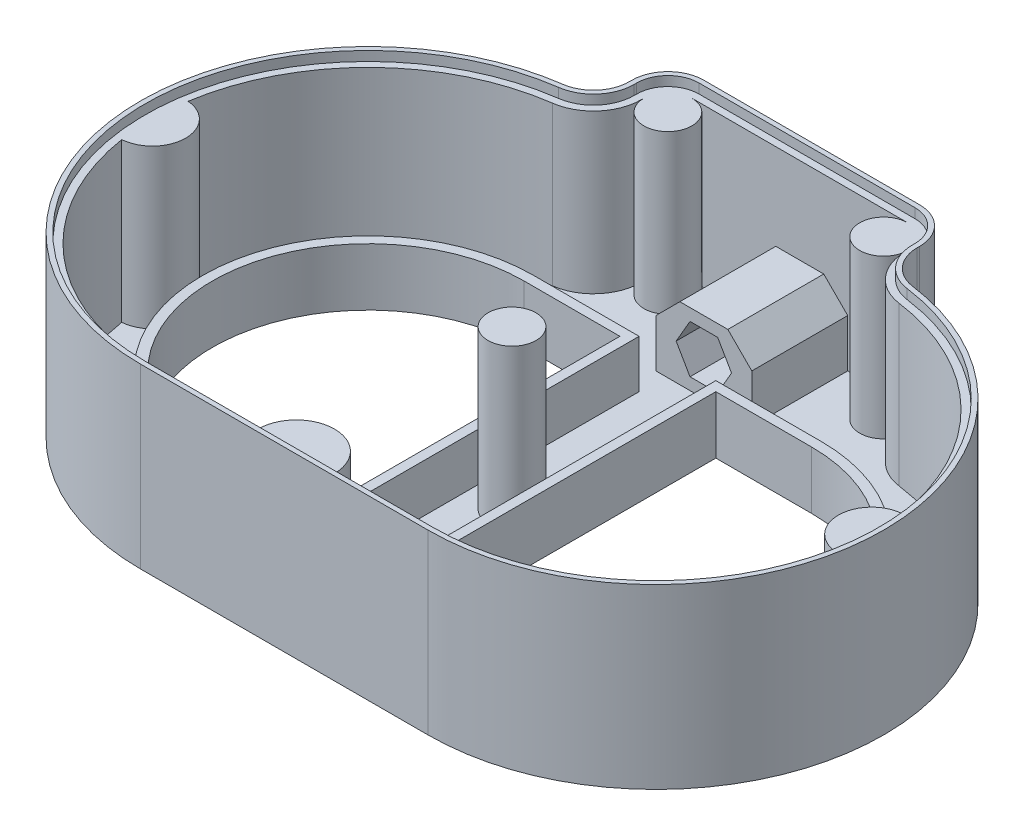
from build123d import *

# Parameters (mm, degrees)
BOSS_EXTRUDE1_DEPTH = 2
EXTRUDE_THIN1_DEPTH = 35
EXTRUDE_THIN3_DEPTH = 10
EXTRUDE_THIN4_DEPTH = 33
BOSS_EXTRUDE4_DEPTH = 33
BOSS_EXTRUDE5_DEPTH = 33
SKETCH12_R          = 5
BOSS_EXTRUDE7_DEPTH = 33
SKETCH13_W          = 20
SKETCH13_H          = 20
BOSS_EXTRUDE8_DEPTH = 15
CUT_EXTRUDE1_DEPTH  = 28
CHAMFER2_SIZE       = 5
SKETCH17_R          = 5
BOSS_EXTRUDE9_DEPTH = 33


with BuildPart() as part:
    # Sketch1 → Boss-Extrude1 (new body)
    with BuildSketch(Plane(origin=(0, 0, 0), x_dir=(1, 0, 0), z_dir=(0, 1, 0))):
        with BuildLine():
            Line((-30, 54.486236794), (-30, 55))
            ThreePointArc((-30, 55), (-27.803300859, 60.303300859), (-22.5, 62.5))
            Line((-22.5, 62.5), (22.5, 62.5))
            ThreePointArc((22.5, 62.5), (27.803300859, 60.303300859), (30, 55))
            Line((30, 55), (30, 54.486236794))
            ThreePointArc((30, 54.486236794), (31.846662289, 49.557771239), (36.477272727, 47.056295413))
            ThreePointArc((36.477272727, 47.056295413), (77.388944028, -3.246226107), (30, -47.5))
            Line((30, -47.5), (-30, -47.5))
            ThreePointArc((-30, -47.5), (-77.388944028, -3.246226107), (-36.477272727, 47.056295413))
            ThreePointArc((-36.477272727, 47.056295413), (-31.846662289, 49.557771239), (-30, 54.486236794))
        make_face()
        with BuildLine():
            Line((-30, 32.5), (-10, 32.5))
            Line((-10, 32.5), (-10, -32.5))
            Line((-10, -32.5), (-30, -32.5))
            ThreePointArc((-30, -32.5), (-62.5, 0), (-30, 32.5))
        make_face(mode=Mode.SUBTRACT)
        with BuildLine():
            Line((10, 32.5), (30, 32.5))
            ThreePointArc((30, 32.5), (62.5, 0), (30, -32.5))
            Line((30, -32.5), (10, -32.5))
            Line((10, -32.5), (10, 32.5))
        make_face(mode=Mode.SUBTRACT)
    extrude(amount=BOSS_EXTRUDE1_DEPTH)

    # Sketch2 → Extrude-Thin1 (add)
    with BuildSketch(Plane(origin=(0, 2, 0), x_dir=(1, 0, 0), z_dir=(0, 1, 0))):
        with BuildLine():
            Line((-30, -47.5), (30, -47.5))
            ThreePointArc((30, -47.5), (77.388944028, -3.246226107), (36.477272727, 47.056295413))
            ThreePointArc((36.477272727, 47.056295413), (31.846662289, 49.557771239), (30, 54.486236794))
            Line((30, 54.486236794), (30, 55))
            ThreePointArc((30, 55), (27.803300859, 60.303300859), (22.5, 62.5))
            Line((22.5, 62.5), (-22.5, 62.5))
            ThreePointArc((-22.5, 62.5), (-27.803300859, 60.303300859), (-30, 55))
            Line((-30, 55), (-30, 54.486236794))
            ThreePointArc((-30, 54.486236794), (-31.846662289, 49.557771239), (-36.477272727, 47.056295413))
            ThreePointArc((-36.477272727, 47.056295413), (-77.388944028, -3.246226107), (-30, -47.5))
        make_face()
        with BuildLine():
            Line((-30, -46.5), (30, -46.5))
            ThreePointArc((30, -46.5), (76.391282048, -3.177884504), (36.340909091, 46.065636562))
            ThreePointArc((36.340909091, 46.065636562), (31.092883928, 48.900642499), (29, 54.486236794))
            Line((29, 54.486236794), (29, 55))
            ThreePointArc((29, 55), (27.096194078, 59.596194078), (22.5, 61.5))
            Line((22.5, 61.5), (-22.5, 61.5))
            ThreePointArc((-22.5, 61.5), (-27.096194078, 59.596194078), (-29, 55))
            Line((-29, 55), (-29, 54.486236794))
            ThreePointArc((-29, 54.486236794), (-31.092883928, 48.900642499), (-36.340909091, 46.065636562))
            ThreePointArc((-36.340909091, 46.065636562), (-76.391282048, -3.177884504), (-30, -46.5))
        make_face(mode=Mode.SUBTRACT)
    extrude(amount=EXTRUDE_THIN1_DEPTH)

    # Sketch5 → Extrude-Thin3 (add)
    with BuildSketch(Plane(origin=(0, 2, 0), x_dir=(1, 0, 0), z_dir=(0, 1, 0))):
        with BuildLine():
            Line((30, -34.5), (8, -34.5))
            Line((8, -34.5), (8, 34.5))
            Line((8, 34.5), (30, 34.5))
            ThreePointArc((30, 34.5), (64.5, 0), (30, -34.5))
        make_face()
        with BuildLine():
            Line((30, -32.5), (10, -32.5))
            Line((10, -32.5), (10, 32.5))
            Line((10, 32.5), (30, 32.5))
            ThreePointArc((30, 32.5), (62.5, 0), (30, -32.5))
        make_face(mode=Mode.SUBTRACT)
    extrude_thin3 = extrude(amount=EXTRUDE_THIN3_DEPTH)

    # Mirror1: Extrude-Thin3 across plane
    add(extrude_thin3.mirror(Plane(origin=(0, 0, 0), x_dir=(0, 0, 1), z_dir=(1, 0, 0))))

    # Sketch6 → Extrude-Thin4 (add)
    with BuildSketch(Plane(origin=(0, 2, 0), x_dir=(1, 0, 0), z_dir=(0, 1, 0))):
        with BuildLine():
            Line((-30, -46.5), (30, -46.5))
            ThreePointArc((30, -46.5), (76.391282048, -3.177884504), (36.340909091, 46.065636562))
            ThreePointArc((36.340909091, 46.065636562), (31.092883928, 48.900642499), (29, 54.486236794))
            Line((29, 54.486236794), (29, 55))
            ThreePointArc((29, 55), (27.096194078, 59.596194078), (22.5, 61.5))
            Line((22.5, 61.5), (-22.5, 61.5))
            ThreePointArc((-22.5, 61.5), (-27.096194078, 59.596194078), (-29, 55))
            Line((-29, 55), (-29, 54.486236794))
            ThreePointArc((-29, 54.486236794), (-31.092883928, 48.900642499), (-36.340909091, 46.065636562))
            ThreePointArc((-36.340909091, 46.065636562), (-76.391282048, -3.177884504), (-30, -46.5))
        make_face()
        with BuildLine():
            Line((-30, -45), (30, -45))
            ThreePointArc((30, -45), (74.894789079, -3.075372101), (36.136363636, 44.579648286))
            ThreePointArc((36.136363636, 44.579648286), (29.962216386, 47.914949388), (27.5, 54.486236794))
            Line((27.5, 54.486236794), (27.5, 55))
            ThreePointArc((27.5, 55), (26.035533906, 58.535533906), (22.5, 60))
            Line((22.5, 60), (-22.5, 60))
            ThreePointArc((-22.5, 60), (-26.035533906, 58.535533906), (-27.5, 55))
            Line((-27.5, 55), (-27.5, 54.486236794))
            ThreePointArc((-27.5, 54.486236794), (-29.962216386, 47.914949388), (-36.136363636, 44.579648286))
            ThreePointArc((-36.136363636, 44.579648286), (-74.894789079, -3.075372101), (-30, -45))
        make_face(mode=Mode.SUBTRACT)
    extrude(amount=EXTRUDE_THIN4_DEPTH)

    # Sketch8 → Boss-Extrude4 (add)
    with BuildSketch(Plane(origin=(0, 2, 0), x_dir=(1, 0, 0), z_dir=(0, 1, 0))):
        with BuildLine():
            ThreePointArc((-74.464958868, 6.918629407), (-68.060713157, 0), (-74.464958868, -6.918629407))
            ThreePointArc((-74.464958868, -6.918629407), (-75, 0), (-74.464958868, 6.918629407))
        make_face()
    boss_extrude4 = extrude(amount=BOSS_EXTRUDE4_DEPTH)

    # Mirror2: Boss-Extrude4 across plane
    add(boss_extrude4.mirror(Plane(origin=(0, 0, 0), x_dir=(0, 0, 1), z_dir=(1, 0, 0))))

    # Sketch9 → Boss-Extrude5 (add)
    with BuildSketch(Plane(origin=(0, 2, 0), x_dir=(1, 0, 0), z_dir=(0, 1, 0))):
        with BuildLine():
            Line((8, -45), (-8, -45))
            ThreePointArc((-8, -45), (0, -37), (8, -45))
        make_face()
    extrude(amount=BOSS_EXTRUDE5_DEPTH)

    # Sketch12 → Boss-Extrude7 (add)
    with BuildSketch(Plane(origin=(0, 2, 0), x_dir=(1, 0, 0), z_dir=(0, 1, 0))):
        with Locations((-22.5, 55)):
            Circle(SKETCH12_R)
        with Locations((22.5, 55)):
            Circle(SKETCH12_R)
    extrude(amount=BOSS_EXTRUDE7_DEPTH)

    # Sketch13 → Boss-Extrude8 (add)
    with BuildSketch(Plane(origin=(0, 2, 0), x_dir=(1, 0, 0), z_dir=(0, 1, 0))):
        with Locations((0, 50)):
            Rectangle(SKETCH13_W, SKETCH13_H)
    extrude(amount=BOSS_EXTRUDE8_DEPTH)

    # Sketch14 → Cut-Extrude1 (cut)
    with BuildSketch(Plane.XY.offset(-40)):
        Polygon((5.773502692, 9.5), (2.886751346, 14.5), (-2.886751346, 14.5), (-5.773502692, 9.5), (-2.886751346, 4.5), (2.886751346, 4.5), align=None)
    extrude(amount=-CUT_EXTRUDE1_DEPTH, mode=Mode.SUBTRACT)

    # Chamfer2
    chamfer2_edges = [part.edges().sort_by_distance(p)[0] for p in [
        (10, 17, -50),
        (-10, 17, -50),
    ]]
    chamfer(chamfer2_edges, length=CHAMFER2_SIZE)

    # Sketch17 → Boss-Extrude9 (add)
    with BuildSketch(Plane(origin=(0, 2, 0), x_dir=(1, 0, 0), z_dir=(0, 1, 0))):
        Circle(SKETCH17_R)
    extrude(amount=BOSS_EXTRUDE9_DEPTH)


solid = part.part
